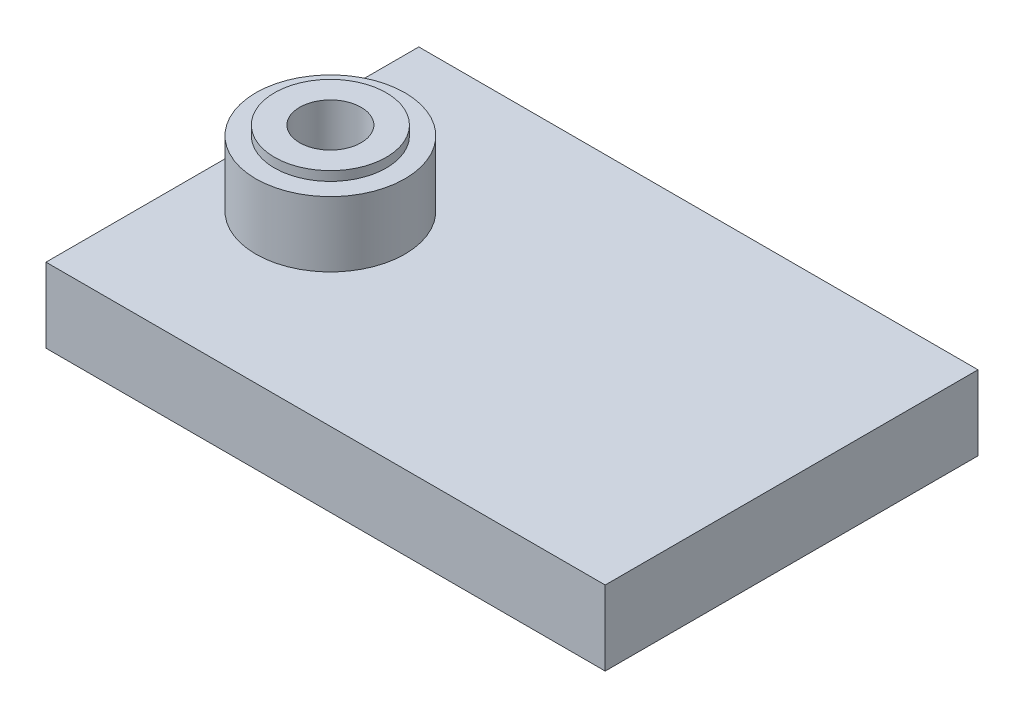
from build123d import *

# Parameters (mm, degrees)
SKETCH1_W             = 30
SKETCH1_H             = 20
BOSS_EXTRUDE1_DEPTH   = 4
SKETCH2_R             = 4
BOSS_EXTRUDE2_DEPTH   = 3.5
M4X0_7_TAPPED_HOLE1_D = 3.3
SKETCH6_R             = 3
SKETCH6_R_2           = 1.65
BOSS_EXTRUDE3_DEPTH   = 0.5


with BuildPart() as part:
    # Sketch1 → Boss-Extrude1 (new body)
    with BuildSketch(Plane(origin=(0, 0, 0), x_dir=(1, 0, 0), z_dir=(0, 1, 0))):
        with Locations((9.74321034, 0)):
            Rectangle(SKETCH1_W, SKETCH1_H)
    extrude(amount=BOSS_EXTRUDE1_DEPTH)

    # Sketch2 → Boss-Extrude2 (add)
    with BuildSketch(Plane(origin=(0, 4, 0), x_dir=(1, 0, 0), z_dir=(0, 1, 0))):
        Circle(SKETCH2_R)
    extrude(amount=BOSS_EXTRUDE2_DEPTH)

    # M4x0.7 Tapped Hole1 (through all)
    with Locations(Plane(origin=(0, 0, 0), x_dir=(-1, 0, 0), z_dir=(0, -1, 0))):
        with Locations((0, 0)):
            Hole(M4X0_7_TAPPED_HOLE1_D / 2)

    # Sketch6 → Boss-Extrude3 (add)
    with BuildSketch(Plane(origin=(0, 7.5, 0), x_dir=(1, 0, 0), z_dir=(0, 1, 0))):
        Circle(SKETCH6_R)
        Circle(SKETCH6_R_2, mode=Mode.SUBTRACT)
    extrude(amount=BOSS_EXTRUDE3_DEPTH)


solid = part.part
